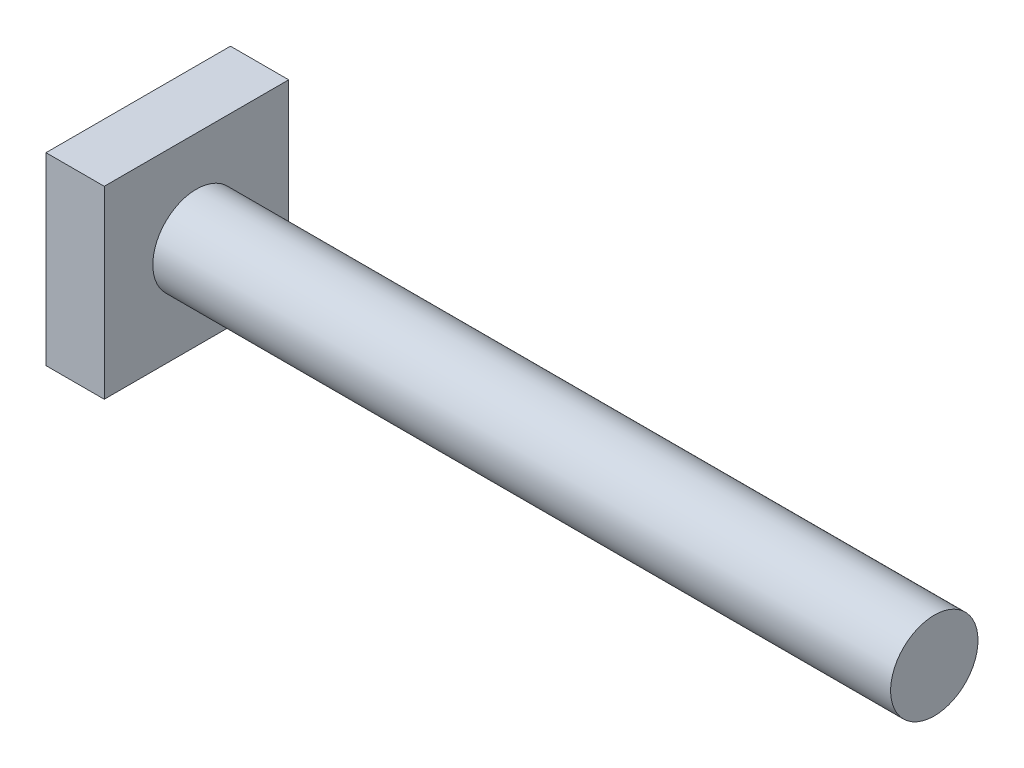
from build123d import *

# Parameters (mm, degrees)
SKETCH1_R           = 114.3
BOSS_EXTRUDE1_DEPTH = 1930.4
SKETCH2_W           = 482.6
SKETCH2_H           = 482.6
BOSS_EXTRUDE2_DEPTH = 152.4


with BuildPart() as part:
    # Sketch1 → Boss-Extrude1 (new body)
    with BuildSketch(Plane(origin=(0, 0, 0), x_dir=(0, 0, -1), z_dir=(1, 0, 0))):
        Circle(SKETCH1_R)
    extrude(amount=BOSS_EXTRUDE1_DEPTH)

    # Sketch2 → Boss-Extrude2 (add)
    with BuildSketch(Plane.ZY):
        Rectangle(SKETCH2_W, SKETCH2_H)
    extrude(amount=BOSS_EXTRUDE2_DEPTH)


solid = part.part
